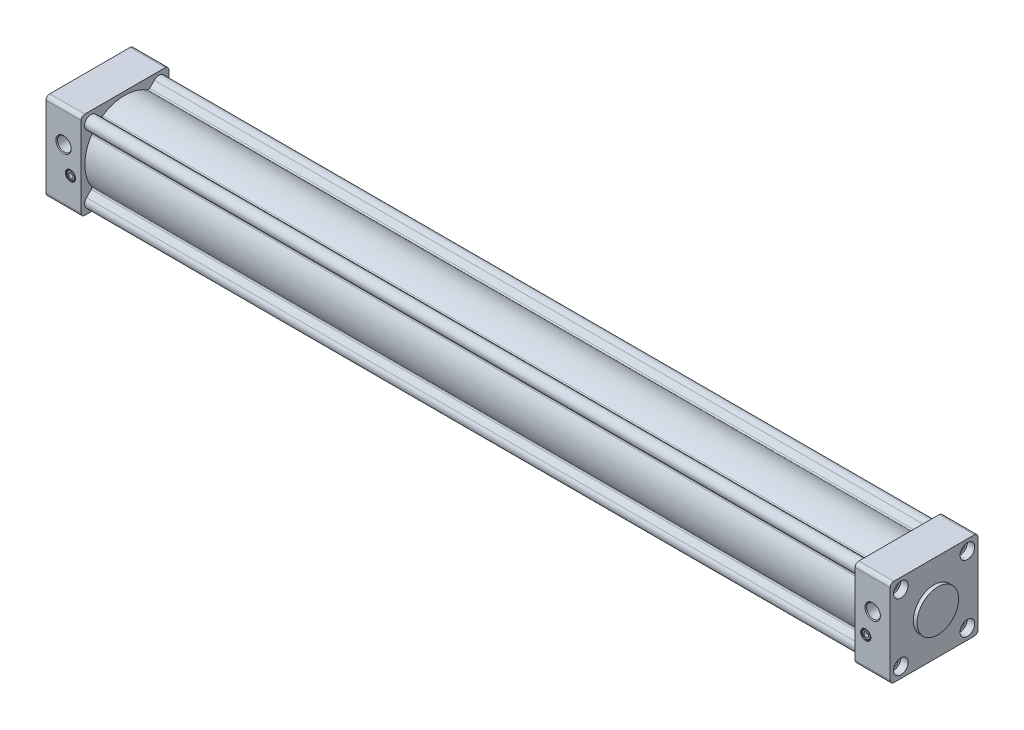
from build123d import *

# Parameters (mm, degrees)
EXTRUDE_1_DEPTH             = 38
SKETCH_3_R                  = 4.35
EXTRUDE_2_DEPTH             = 838
EXTRUDE_START               = -38
EXTRUDE_3_DEPTH             = 38
SKETCH_5_W                  = 42
SKETCH_5_H                  = 22.5
PATTERN_LINEAR_1_COUNT      = 2
PATTERN_LINEAR_1_PITCH      = 72
PATTERN_LINEAR_1_COUNT_DIR2 = 2
PATTERN_LINEAR_1_PITCH_DIR2 = 72
PATTERN_LINEAR_2_COUNT      = 2
PATTERN_LINEAR_2_PITCH      = 72
PATTERN_LINEAR_2_COUNT_DIR2 = 2
PATTERN_LINEAR_2_PITCH_DIR2 = 72


with BuildPart() as part:
    # 草图1 → 凸台-拉伸1 (new body)
    with BuildSketch(Plane(origin=(0, 0, 0), x_dir=(0, 0, -1), z_dir=(1, 0, 0))):
        with BuildLine():
            Line((-43.5, -47.5), (43.5, -47.5))
            ThreePointArc((43.5, -47.5), (46.328427125, -46.328427125), (47.5, -43.5))
            Line((47.5, -43.5), (47.5, 43.5))
            ThreePointArc((47.5, 43.5), (46.328427125, 46.328427125), (43.5, 47.5))
            Line((43.5, 47.5), (-43.5, 47.5))
            ThreePointArc((-43.5, 47.5), (-46.328427125, 46.328427125), (-47.5, 43.5))
            Line((-47.5, 43.5), (-47.5, -43.5))
            ThreePointArc((-47.5, -43.5), (-46.328427125, -46.328427125), (-43.5, -47.5))
        make_face()
    extrude(amount=EXTRUDE_1_DEPTH)

    # 草图2 → 旋转1 (revolve)
    with BuildSketch(Plane(origin=(0, 0, 0), x_dir=(1, 0, 0), z_dir=(0, 1, 0))):
        with BuildLine():
            Line((-20, 0), (-20, 19))
            ThreePointArc((-20, 19), (-19.707106781, 19.707106781), (-19, 20))
            Line((-19, 20), (-5, 20))
            Line((-5, 20), (-5, 21.5))
            ThreePointArc((-5, 21.5), (-4.707106781, 22.207106781), (-4, 22.5))
            Line((-4, 22.5), (38, 22.5))
            Line((38, 22.5), (38, 0))
            Line((38, 0), (-20, 0))
        make_face()
    revolve(axis=Axis((38, 0, 0), (-1, 0, 0)))

    # 草图3 → 凸台-拉伸2 (add)
    with BuildSketch(Plane(origin=(38, 0, 0), x_dir=(0, 0, -1), z_dir=(1, 0, 0))):
        with BuildLine():
            Line((-31.780252532, -41.679747468), (-26.587928413, -36.48742335))
            ThreePointArc((-26.587928413, -36.48742335), (-25.372501394, -35.911540455), (-24.067177934, -36.235630894))
            ThreePointArc((-24.067177934, -36.235630894), (0, -43.5), (24.067177934, -36.235630894))
            ThreePointArc((24.067177934, -36.235630894), (25.372501394, -35.911540455), (26.587928413, -36.48742335))
            Line((26.587928413, -36.48742335), (31.780252532, -41.679747468))
            ThreePointArc((31.780252532, -41.679747468), (41.679747468, -41.679747468), (41.679747468, -31.780252532))
            Line((41.679747468, -31.780252532), (36.48742335, -26.587928413))
            ThreePointArc((36.48742335, -26.587928413), (35.911540455, -25.372501394), (36.235630894, -24.067177934))
            ThreePointArc((36.235630894, -24.067177934), (43.5, 0), (36.235630894, 24.067177934))
            ThreePointArc((36.235630894, 24.067177934), (35.911540455, 25.372501394), (36.48742335, 26.587928413))
            Line((36.48742335, 26.587928413), (41.679747468, 31.780252532))
            ThreePointArc((41.679747468, 31.780252532), (41.679747468, 41.679747468), (31.780252532, 41.679747468))
            Line((31.780252532, 41.679747468), (26.587928413, 36.48742335))
            ThreePointArc((26.587928413, 36.48742335), (25.372501394, 35.911540455), (24.067177934, 36.235630894))
            ThreePointArc((24.067177934, 36.235630894), (0, 43.5), (-24.067177934, 36.235630894))
            ThreePointArc((-24.067177934, 36.235630894), (-25.372501394, 35.911540455), (-26.587928413, 36.48742335))
            Line((-26.587928413, 36.48742335), (-31.780252532, 41.679747468))
            ThreePointArc((-31.780252532, 41.679747468), (-41.679747384, 41.679747384), (-41.679747468, 31.780252532))
            Line((-41.679747468, 31.780252532), (-36.48742335, 26.587928413))
            ThreePointArc((-36.48742335, 26.587928413), (-35.911540455, 25.372501394), (-36.235630894, 24.067177934))
            ThreePointArc((-36.235630894, 24.067177934), (-43.5, 0), (-36.235630894, -24.067177934))
            ThreePointArc((-36.235630894, -24.067177934), (-35.911540455, -25.372501394), (-36.48742335, -26.587928413))
            Line((-36.48742335, -26.587928413), (-41.679747468, -31.780252532))
            ThreePointArc((-41.679747468, -31.780252532), (-41.679747384, -41.679747384), (-31.780252532, -41.679747468))
        make_face()
        with Locations((36, 36)):
            Circle(SKETCH_3_R, mode=Mode.SUBTRACT)
        with Locations((36, -36)):
            Circle(SKETCH_3_R, mode=Mode.SUBTRACT)
        with Locations((-36, 36)):
            Circle(SKETCH_3_R, mode=Mode.SUBTRACT)
        with Locations((-36, -36)):
            Circle(SKETCH_3_R, mode=Mode.SUBTRACT)
    extrude(amount=EXTRUDE_2_DEPTH)

    # 草图4 → 凸台-拉伸3 (add)
    with BuildSketch(Plane(origin=(914, 0, 0), x_dir=(0, 0, -1), z_dir=(1, 0, 0)).offset(EXTRUDE_START)):
        with BuildLine():
            Line((-43.5, -47.5), (43.5, -47.5))
            ThreePointArc((43.5, -47.5), (46.328427125, -46.328427125), (47.5, -43.5))
            Line((47.5, -43.5), (47.5, 43.5))
            ThreePointArc((47.5, 43.5), (46.328427125, 46.328427125), (43.5, 47.5))
            Line((43.5, 47.5), (-43.5, 47.5))
            ThreePointArc((-43.5, 47.5), (-46.328427125, 46.328427125), (-47.5, 43.5))
            Line((-47.5, 43.5), (-47.5, -43.5))
            ThreePointArc((-47.5, -43.5), (-46.328427125, -46.328427125), (-43.5, -47.5))
        make_face()
    extrude(amount=EXTRUDE_3_DEPTH)

    # 草图5 → 旋转2 (revolve)
    with BuildSketch(Plane.XY):
        with Locations((897, 11.25)):
            Rectangle(SKETCH_5_W, SKETCH_5_H)
    revolve(axis=Axis((918, 0, 0), (-1, 0, 0)))

    # 草图6 → 切除-旋转1 (revolve, cut)
    with BuildSketch(Plane(origin=(0, 11.5, 0), x_dir=(1, 0, 0), z_dir=(0, 1, 0))):
        Polygon((19, -47.5), (10.669, -47.5), (11.525, -46.644), (11.525, -29.5), (19, -25.184306738), align=None)
    revolve(axis=Axis((19, 11.5, 25.184306738), (0, 0, 1)), mode=Mode.SUBTRACT)

    # 草图7 → 切除-旋转2 (revolve, cut)
    with BuildSketch(Plane(origin=(0, 11.5, 0), x_dir=(1, 0, 0), z_dir=(0, 1, 0))):
        Polygon((895, -47.5), (886.669, -47.5), (887.525, -46.644), (887.525, -29.5), (895, -25.184306738), align=None)
    revolve(axis=Axis((895, 11.5, 25.184306738), (0, 0, 1)), mode=Mode.SUBTRACT)

    # 草图8 → 切除-旋转3 (revolve, cut)
    with BuildSketch(Plane(origin=(0, -14, 0), x_dir=(1, 0, 0), z_dir=(0, 1, 0))):
        Polygon((26.5, -47.5), (20.95, -47.5), (21.45, -47), (21.45, -44), (21.95, -44), (21.95, -46.5), (22.45, -47), (24, -47), (24, -44), (26.5, -44), align=None)
    revolve(axis=Axis((26.5, -14, 44), (0, 0, 1)), mode=Mode.SUBTRACT)

    # 草图9 → 切除-旋转4 (revolve, cut)
    with BuildSketch(Plane(origin=(0, -14, 0), x_dir=(1, 0, 0), z_dir=(0, 1, 0))):
        Polygon((887.5, -47.5), (881.95, -47.5), (882.45, -47), (882.45, -44), (882.95, -44), (882.95, -46.5), (883.45, -47), (885, -47), (885, -44), (887.5, -44), align=None)
    revolve(axis=Axis((887.5, -14, 44), (0, 0, 1)), mode=Mode.SUBTRACT)

    # 草图10 → 切除-旋转5 (revolve, cut)
    with BuildSketch(Plane.XY.offset(-36)):
        Polygon((20, -36), (20, -40.188), (8.812, -40.188), (8, -41), (8, -43.95), (0, -43.95), (0, -36), align=None)
    cut_revolve_5 = revolve(axis=Axis((0, -36, -36), (1, 0, 0)), mode=Mode.SUBTRACT)

    # 阵列(线性)1: Cut-Revolve 5 2 × 2
    with Locations(*[(0, i * PATTERN_LINEAR_1_PITCH, j * PATTERN_LINEAR_1_PITCH_DIR2) for i in range(PATTERN_LINEAR_1_COUNT) for j in range(PATTERN_LINEAR_1_COUNT_DIR2) if (i, j) != (0, 0)]):
        add(cut_revolve_5, mode=Mode.SUBTRACT)

    # 草图12 → 切除-旋转6 (revolve, cut)
    with BuildSketch(Plane.XY.offset(-36)):
        Polygon((914, -36), (914, -43.95), (906, -43.95), (906, -41), (905.188, -40.188), (894, -40.188), (894, -36), align=None)
    cut_revolve_6 = revolve(axis=Axis((894, -36, -36), (1, 0, 0)), mode=Mode.SUBTRACT)

    # 阵列(线性)2: Cut-Revolve 6 2 × 2
    with Locations(*[(0, i * PATTERN_LINEAR_2_PITCH, j * PATTERN_LINEAR_2_PITCH_DIR2) for i in range(PATTERN_LINEAR_2_COUNT) for j in range(PATTERN_LINEAR_2_COUNT_DIR2) if (i, j) != (0, 0)]):
        add(cut_revolve_6, mode=Mode.SUBTRACT)

    # 草图14 → 切除-旋转7 (revolve, cut)
    with BuildSketch(Plane.XY):
        Polygon((-20, 0), (-20, 12.5), (-1.5, 12.5), (-1.5, 18.2), (34.5, 18.2), (34.5, 40), (879.5, 40), (879.5, 18.2), (915.5, 18.2), (915.5, 0), align=None)
    revolve(axis=Axis((915.5, 0, 0), (-1, 0, 0)), mode=Mode.SUBTRACT)


solid = part.part
